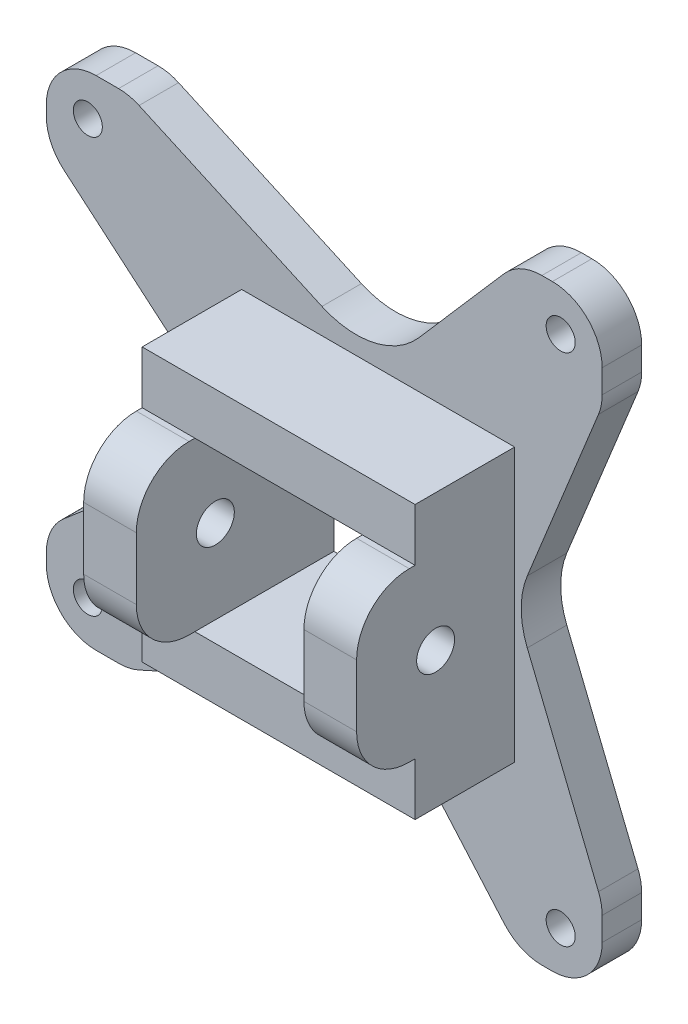
from build123d import *

# Parameters (mm, degrees)
SKETCH1_R           = 1.75
SKETCH1_W           = 20.2
SKETCH1_H           = 20.2
BOSS_EXTRUDE1_DEPTH = 4.7625
FILLET1_R           = 6
FILLET2_R           = 10
SKETCH2_W           = 6.35
SKETCH2_H           = 20.2
BOSS_EXTRUDE2_DEPTH = 19.05
SKETCH3_R           = 2.286
CUT_EXTRUDE1_DEPTH  = 57.45
SKETCH4_W           = 32.9
SKETCH4_H           = 6.35
BOSS_EXTRUDE3_DEPTH = 12
FILLET5_R           = 6.35


with BuildPart() as part:
    # Sketch1 → Boss-Extrude1 (new body)
    with BuildSketch(Plane.XY):
        Polygon((-30, -30), (0, -16.45), (17, -36), (27, -36), (27, -26), (16.45, 0), (27, 26), (27, 36), (17, 36), (0, 16.45), (-30, 30), (-40, 30), (-40, 20), (-16.45, 0), (-40, -20), (-40, -30), align=None)
        with Locations((22, 31)):
            Circle(SKETCH1_R, mode=Mode.SUBTRACT)
        with Locations((22, -31)):
            Circle(SKETCH1_R, mode=Mode.SUBTRACT)
        with Locations((-35, 25)):
            Circle(SKETCH1_R, mode=Mode.SUBTRACT)
        with Locations((-35, -25)):
            Circle(SKETCH1_R, mode=Mode.SUBTRACT)
        Rectangle(SKETCH1_W, SKETCH1_H, mode=Mode.SUBTRACT)
    extrude(amount=BOSS_EXTRUDE1_DEPTH)

    # Fillet1
    fillet1_edges = [part.edges().sort_by_distance(p)[0] for p in [
        (17, 36, 2.38125),
        (27, 36, 2.38125),
        (27, 26, 2.38125),
        (27, -26, 2.38125),
        (27, -36, 2.38125),
        (17, -36, 2.38125),
        (-30, -30, 2.38125),
        (-40, -30, 2.38125),
        (-40, -20, 2.38125),
        (-40, 20, 2.38125),
        (-40, 30, 2.38125),
        (-30, 30, 2.38125),
    ]]
    fillet(fillet1_edges, radius=FILLET1_R)

    # Fillet2
    fillet2_edges = [part.edges().sort_by_distance(p)[0] for p in [
        (0, 16.45, 2.38125),
        (16.45, 0, 2.38125),
        (0, -16.45, 2.38125),
        (-16.45, 0, 2.38125),
    ]]
    fillet(fillet2_edges, radius=FILLET2_R)

    # Sketch2 → Boss-Extrude2 (add)
    with BuildSketch(Plane.XY.offset(4.7625)):
        with Locations((13.275, 0)):
            Rectangle(SKETCH2_W, SKETCH2_H)
        with Locations((-13.275, 0)):
            Rectangle(SKETCH2_W, SKETCH2_H)
    extrude(amount=BOSS_EXTRUDE2_DEPTH)

    # Sketch3 → Cut-Extrude1 (cut, through all)
    with BuildSketch(Plane(origin=(16.45, 0, 0), x_dir=(0, 0, -1), z_dir=(1, 0, 0))):
        with Locations((-14.2875, 0)):
            Circle(SKETCH3_R)
    extrude(amount=-CUT_EXTRUDE1_DEPTH, mode=Mode.SUBTRACT)

    # Sketch4 → Boss-Extrude3 (add)
    with BuildSketch(Plane.XY.offset(4.7625)):
        with Locations((0, 13.275)):
            Rectangle(SKETCH4_W, SKETCH4_H)
        with Locations((0, -13.275)):
            Rectangle(SKETCH4_W, SKETCH4_H)
    extrude(amount=BOSS_EXTRUDE3_DEPTH)

    # Fillet5
    fillet5_edges = [part.edges().sort_by_distance(p)[0] for p in [
        (13.275, -10.1, 23.8125),
        (13.275, 10.1, 23.8125),
        (-13.275, 10.1, 23.8125),
        (-13.275, -10.1, 23.8125),
    ]]
    fillet(fillet5_edges, radius=FILLET5_R)


solid = part.part
